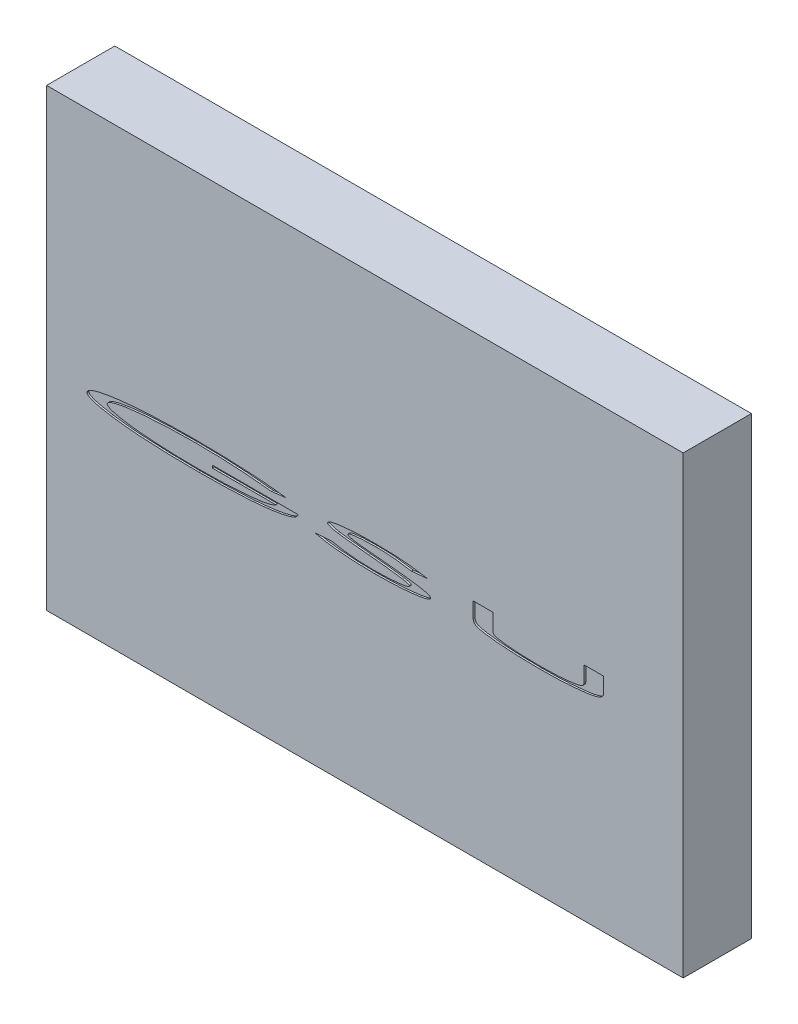
from build123d import *

# Parameters (mm, degrees)
SKETCH1_W           = 88.9
SKETCH1_H           = 63.5
BOSS_EXTRUDE1_DEPTH = 9.525
CUT_EXTRUDE1_DEPTH  = 0.254
SKETCH3_W           = 3.175
SKETCH3_H           = 8.119404955
BOSS_EXTRUDE2_DEPTH = 2.54


with BuildPart() as part:
    # Sketch1 → Boss-Extrude1 (new body)
    with BuildSketch(Plane.XY):
        with Locations((44.45, 31.75)):
            Rectangle(SKETCH1_W, SKETCH1_H)
    extrude(amount=BOSS_EXTRUDE1_DEPTH)

    # Sketch2 → Cut-Extrude1 (cut)
    with BuildSketch(Plane.XY.offset(9.525)):
        with BuildLine():
            Line((33.498393787, 30.350809785), (31.359972313, 30.095601452))
            add(Edge.make_bspline(
                [(31.359972313, 30.095601452), (31.164171604, 30.119137473), (30.76811553, 30.166744982), (30.166706814, 30.231507474), (29.551570327, 30.292530308), (28.922670707, 30.349476787), (28.279673094, 30.401057302), (27.622703221, 30.448744443), (26.95193934, 30.492152968), (26.270413682, 30.531082925), (25.584475752, 30.566046418), (24.8997008, 30.596305187), (24.219346058, 30.621254482), (23.543467912, 30.64262667), (22.87199923, 30.658484676), (22.204993407, 30.670596571), (21.542180258, 30.677844204), (21.101861062, 30.678572037), (20.88240821, 30.678934785)],
                knots=[0, 0, 0, 0, 0.901543175, 1.823597338, 2.765180975, 3.727432813, 4.710338068, 5.714059156, 6.738658915, 7.783129777, 8.834722104, 9.878489466, 10.916616063, 11.947049738, 12.969801264, 13.987077713, 14.996769752, 16, 16, 16, 16], degree=3))
            add(Edge.make_bspline(
                [(20.88240821, 30.678934785), (20.611771671, 30.678533034), (20.073752111, 30.677734362), (19.271653772, 30.667120378), (18.479352252, 30.652140424), (17.696872737, 30.630335379), (16.924205291, 30.602371737), (16.161122982, 30.567991839), (15.407841368, 30.527529146), (14.787679668, 30.488026119), (14.300667861, 30.454471855), (13.946820229, 30.427921112), (13.603534675, 30.399680287), (13.2706852, 30.371208245), (12.948211691, 30.340771958), (12.635913932, 30.310284713), (12.33418342, 30.278044793), (12.043035781, 30.244118788), (11.762030661, 30.210173759), (11.491453521, 30.174141603), (11.231251489, 30.137984115), (10.981402573, 30.100099786), (10.742115125, 30.060810447), (10.512990968, 30.021026291), (10.294519747, 29.979549511), (10.086678221, 29.937762848), (9.890320157, 29.895069357), (9.70638354, 29.851748365), (9.535056174, 29.808247615), (9.376422701, 29.765051074), (9.230465837, 29.721053436), (9.097283349, 29.676132736), (8.976664812, 29.631706908), (8.868950604, 29.586549428), (8.77339938, 29.542460718), (8.690800507, 29.496602594), (8.620438516, 29.451020239), (8.563050499, 29.404328981), (8.516857088, 29.358499552), (8.484728301, 29.310868581), (8.463756158, 29.262686858), (8.461184714, 29.22967111), (8.459932249, 29.213590234)],
                knots=[0, 0, 0, 0, 2.560295728, 5.08981227, 7.588659566, 10.05703186, 12.495103614, 14.903055874, 17.283284305, 19.631568545, 20.781808933, 21.901495378, 22.988464749, 24.04036836, 25.061839365, 26.052710236, 27.008843358, 27.932504729, 28.825690343, 29.686534002, 30.514814534, 31.310916308, 32.077131017, 32.808835325, 33.510877328, 34.180795271, 34.814382034, 35.411801099, 35.968416347, 36.486552916, 36.96706216, 37.410334263, 37.81609033, 38.182768289, 38.515088168, 38.811008814, 39.0759172, 39.306927123, 39.510190308, 39.688634681, 39.84834428, 40, 40, 40, 40], degree=3))
            add(Edge.make_bspline(
                [(8.459932249, 29.213590234), (8.461166338, 29.19727328), (8.463721069, 29.163494989), (8.485409294, 29.114021684), (8.51903134, 29.065208018), (8.5666102, 29.017751276), (8.625900688, 28.96982992), (8.698872961, 28.923518631), (8.784051754, 28.876108338), (8.882998824, 28.830857022), (8.99438579, 28.784160116), (9.119082119, 28.738142415), (9.257270777, 28.693052973), (9.407949999, 28.647338125), (9.571943548, 28.602656693), (9.74885068, 28.557843116), (9.939226664, 28.513902794), (10.141850219, 28.469876671), (10.356139437, 28.426419647), (10.581012117, 28.384462539), (10.815993417, 28.344093233), (11.060839734, 28.303782071), (11.315938945, 28.265725943), (11.580837619, 28.227348741), (11.856053676, 28.192085617), (12.140952083, 28.157079166), (12.43584492, 28.122487285), (12.740855683, 28.08964447), (13.055907253, 28.058143326), (13.38103884, 28.028182717), (13.716141724, 27.998528868), (14.061344864, 27.970597172), (14.41661488, 27.944136901), (14.906342471, 27.90905177), (15.533373432, 27.870463839), (16.300141908, 27.828517361), (17.084763843, 27.794527392), (17.887123565, 27.76682424), (18.706972206, 27.743855014), (19.544393733, 27.729219572), (20.399541334, 27.718557772), (20.97565393, 27.717786074), (21.266622954, 27.717396324)],
                knots=[0, 0, 0, 0, 0.149261413, 0.308991208, 0.488073047, 0.691343065, 0.923166096, 1.186735423, 1.483418409, 1.817363135, 2.184659931, 2.591878477, 3.036859013, 3.518657845, 4.036963324, 4.596752705, 5.193559406, 5.830130172, 6.49984963, 7.200332085, 7.929610585, 8.688147997, 9.477804936, 10.296861546, 11.144803288, 12.024397377, 12.931424197, 13.869946708, 14.840028511, 15.837455419, 16.866734368, 17.927713592, 19.016159642, 20.136539519, 22.434085388, 24.782026112, 27.184624724, 29.642192438, 32.150682135, 34.712293212, 37.329412879, 40, 40, 40, 40], degree=3))
            add(Edge.make_bspline(
                [(21.266622954, 27.717396324), (21.443306298, 27.717705721), (21.793170702, 27.718318383), (22.312939208, 27.721990144), (22.822433762, 27.727285388), (23.321632785, 27.735914276), (23.810319462, 27.746408156), (24.288739593, 27.758777137), (24.756850537, 27.774387035), (25.214689459, 27.791892583), (25.662270192, 27.811277419), (26.099526756, 27.833883997), (26.526518073, 27.858403169), (26.943029925, 27.884767236), (27.349194044, 27.914433701), (27.74510561, 27.945941574), (28.130791573, 27.979242834), (28.504656196, 28.016048918), (28.864005268, 28.052995455), (29.205802046, 28.093643703), (29.528975208, 28.133463694), (29.833143375, 28.176796036), (30.11872129, 28.219496768), (30.385046232, 28.265452416), (30.632682215, 28.311380875), (30.861478878, 28.358571004), (31.071211746, 28.408750089), (31.262520992, 28.458417683), (31.434828066, 28.510504037), (31.588531557, 28.562821804), (31.722899166, 28.618505699), (31.838957405, 28.674087426), (31.937191713, 28.73046153), (31.992116072, 28.774067505), (32.017624556, 28.794319401)],
                knots=[0, 0, 0, 0, 1.559717219, 3.088517121, 4.588489478, 6.057632978, 7.495954163, 8.903485704, 10.282390928, 11.630589239, 12.948120933, 14.237193767, 15.495701499, 16.723694437, 17.921374234, 19.090723157, 20.229747177, 21.338712889, 22.407039789, 23.418633316, 24.377225284, 25.281416395, 26.130789363, 26.926158043, 27.667056146, 28.354106116, 28.9881293, 29.570617496, 30.098632808, 30.576887523, 31.003318101, 31.38163322, 31.712812309, 32, 32, 32, 32], degree=3))
            Line((32.017624556, 28.794319401), (23.177880967, 28.794319401))
            Line((23.177880967, 28.794319401), (23.177880967, 29.15329376))
            Line((23.177880967, 29.15329376), (35.113778403, 29.15329376))
            add(Edge.make_bspline(
                [(35.113778403, 29.15329376), (35.112165747, 29.136151001), (35.108920439, 29.101652913), (35.094942791, 29.050794686), (35.074620932, 29.000433021), (35.045795333, 28.951236223), (35.010921679, 28.902145355), (34.968240774, 28.854131852), (34.917931033, 28.807170724), (34.860782184, 28.760553067), (34.796062475, 28.714559828), (34.724397553, 28.669462118), (34.645101774, 28.625174447), (34.559052484, 28.581194006), (34.46571577, 28.537430089), (34.3644653, 28.495992606), (34.256465375, 28.453539673), (34.140849559, 28.412492741), (34.018118025, 28.37184628), (33.888162157, 28.331823454), (33.750897374, 28.292742263), (33.606435946, 28.254217094), (33.454750832, 28.216313246), (33.295788393, 28.179249044), (33.129284381, 28.14299028), (32.955785876, 28.106234601), (32.77456303, 28.071350647), (32.586086584, 28.037334685), (32.390629855, 28.002489202), (32.187603732, 27.970029021), (31.977561558, 27.93690971), (31.760261729, 27.904480302), (31.535538878, 27.874056135), (31.223281979, 27.832209943), (30.818610896, 27.782869678), (30.317450596, 27.728473304), (29.796479607, 27.677405974), (29.255688195, 27.629535197), (28.694945387, 27.586517385), (28.114195157, 27.546274751), (27.513739947, 27.510932014), (26.893234797, 27.478631988), (26.252870525, 27.44986505), (25.592394021, 27.425313397), (24.912263698, 27.405529694), (24.212322992, 27.387545976), (23.492484872, 27.374381875), (22.752551437, 27.365524127), (21.99276055, 27.359735098), (21.47953133, 27.358863377), (21.219647794, 27.358421965)],
                knots=[0, 0, 0, 0, 0.173287774, 0.348724318, 0.529413354, 0.719357524, 0.922025509, 1.135679417, 1.365673011, 1.615149832, 1.878618212, 2.165563057, 2.468311752, 2.793895887, 3.139613543, 3.507144469, 3.896528235, 4.309367421, 4.743716078, 5.199789029, 5.680036688, 6.182366302, 6.706917049, 7.256105144, 7.827751413, 8.424737021, 9.043885989, 9.688069709, 10.35544506, 11.045264933, 11.76067648, 12.499023304, 13.260026326, 14.046711347, 15.674976355, 17.369487022, 19.128399383, 20.951901464, 22.842327179, 24.797685087, 26.820321237, 28.905814273, 31.061333963, 33.282186671, 35.568496213, 37.920489349, 40.340481978, 42.826216353, 45.380154639, 48, 48, 48, 48], degree=3))
            add(Edge.make_bspline(
                [(21.219647794, 27.358421965), (21.060960162, 27.358531984), (20.745453166, 27.358750726), (20.275469653, 27.361261628), (19.811550898, 27.363460253), (19.353959656, 27.368937668), (18.902429153, 27.374201389), (18.457214753, 27.381283229), (18.018310218, 27.389689088), (17.585712262, 27.399403211), (17.159444262, 27.410960368), (16.739437702, 27.422282626), (16.325573154, 27.436884875), (15.917965202, 27.45124961), (15.51645189, 27.467392209), (15.121275868, 27.485224429), (14.732329097, 27.50281258), (14.349807979, 27.523848386), (13.973468415, 27.544170647), (13.60310388, 27.567922983), (13.238945545, 27.591371283), (12.881133217, 27.616616806), (12.529680333, 27.643612028), (12.184396823, 27.670280968), (11.845377395, 27.700377396), (11.512747314, 27.730078656), (11.186266528, 27.761790969), (10.866075239, 27.794674213), (10.551952871, 27.828925747), (10.24422244, 27.865012201), (9.94259909, 27.900858589), (9.647330043, 27.940070822), (9.358113855, 27.978730246), (9.167571718, 28.006539016), (9.073413819, 28.020280939)],
                knots=[0, 0, 0, 0, 1.25133571, 2.487939159, 3.706123477, 4.909611371, 6.096535522, 7.266927036, 8.420799223, 9.558165973, 10.67904179, 11.783388008, 12.871328107, 13.944598398, 14.999593462, 16.040014038, 17.063949564, 18.069755188, 19.060939775, 20.035893706, 20.996252006, 21.938473619, 22.864422433, 23.775814375, 24.669297784, 25.54825852, 26.409214049, 27.255865198, 28.086411598, 28.900889254, 29.699112994, 30.481570037, 31.249655866, 32, 32, 32, 32], degree=3))
            add(Edge.make_bspline(
                [(9.073413819, 28.020280939), (9.002821451, 28.030948841), (8.863920321, 28.051939547), (8.65898321, 28.084360287), (8.460707258, 28.116310262), (8.269068532, 28.14932842), (8.084250404, 28.183027886), (7.906163058, 28.216686736), (7.734764249, 28.250157721), (7.570307722, 28.284671954), (7.412214603, 28.318815484), (7.261068436, 28.353962412), (7.116616526, 28.38896583), (6.978874013, 28.423960499), (6.847917805, 28.459517314), (6.723705746, 28.496221635), (6.6060849, 28.532507059), (6.4949292, 28.568853242), (6.390772452, 28.606073071), (6.293056441, 28.642902267), (6.202551995, 28.681061156), (6.118483094, 28.718637865), (6.040968491, 28.756550699), (5.970140123, 28.794845054), (5.906321054, 28.834069052), (5.849334012, 28.873530503), (5.798381633, 28.912401615), (5.754965357, 28.952706984), (5.717124387, 28.992404523), (5.687027624, 29.033420988), (5.66245576, 29.074185425), (5.64554965, 29.115815061), (5.635260702, 29.157705481), (5.633753702, 29.185724881), (5.633009172, 29.199567798)],
                knots=[0, 0, 0, 0, 1.822223928, 3.585500351, 5.295765701, 6.948182563, 8.548774514, 10.090715014, 11.574083748, 13.00601978, 14.379615137, 15.702136353, 16.96661525, 18.173208705, 19.329414063, 20.429849322, 21.478885095, 22.471094327, 23.414440792, 24.301811497, 25.136002493, 25.92094558, 26.651902042, 27.337909187, 27.975277371, 28.562676203, 29.106772842, 29.609149393, 30.073428365, 30.504111874, 30.905148094, 31.285089726, 31.646800292, 32, 32, 32, 32], degree=3))
            add(Edge.make_bspline(
                [(5.633009172, 29.199567798), (5.634569981, 29.220338011), (5.637784864, 29.263119523), (5.662908983, 29.325947898), (5.702475987, 29.387591529), (5.757657554, 29.448095091), (5.828158559, 29.507487006), (5.913195444, 29.567080496), (6.014555261, 29.624901621), (6.130735055, 29.682759338), (6.262472388, 29.739936414), (6.40887957, 29.797632147), (6.571346245, 29.853040326), (6.748654513, 29.90933313), (6.941939107, 29.96432186), (7.150289493, 30.019874815), (7.374473381, 30.073296434), (7.612732167, 30.127487749), (7.864879994, 30.179426831), (8.128826425, 30.231685793), (8.404729148, 30.281156408), (8.69197947, 30.329488898), (8.990685375, 30.376394064), (9.30060096, 30.421933968), (9.621969917, 30.466037711), (9.954730254, 30.509013449), (10.299346951, 30.549117858), (10.655179006, 30.589642079), (11.022698099, 30.626795925), (11.40120371, 30.664595476), (11.791371937, 30.698993049), (12.19280255, 30.733871588), (12.606051926, 30.76579249), (13.030007747, 30.796547808), (13.463286912, 30.826061045), (13.904300427, 30.853408466), (14.352349538, 30.878396289), (14.80735838, 30.9024521), (15.269638968, 30.924188473), (15.738949134, 30.94352841), (16.215229625, 30.962021296), (16.698545397, 30.978054925), (17.188867651, 30.99212296), (17.68644581, 31.003777003), (18.191012552, 31.014594553), (18.702611018, 31.022661389), (19.221203454, 31.029958286), (19.746817048, 31.034738151), (20.279673704, 31.03766559), (20.637248901, 31.037827607), (20.817203883, 31.037909144)],
                knots=[0, 0, 0, 0, 0.192161926, 0.395806149, 0.618828282, 0.868950107, 1.15168167, 1.472089154, 1.830351652, 2.232495172, 2.67493025, 3.161398823, 3.691095085, 4.266047719, 4.886016421, 5.554025888, 6.265084938, 7.022565255, 7.819360025, 8.651829877, 9.517165752, 10.418044808, 11.352446437, 12.320470786, 13.322207914, 14.359888197, 15.431181917, 16.538821552, 17.6802356, 18.855927486, 20.065527521, 21.311632913, 22.591761846, 23.908296688, 25.252627148, 26.618158967, 28.00493704, 29.413115926, 30.842613354, 32.295633707, 33.767966254, 35.261720121, 36.779096121, 38.315795872, 39.876227354, 41.458201966, 43.05961064, 44.684778251, 46.331565847, 48, 48, 48, 48], degree=3))
            add(Edge.make_bspline(
                [(20.817203883, 31.037909144), (21.108171102, 31.037326557), (21.685908828, 31.036169786), (22.546200637, 31.028243301), (23.393637374, 31.015667738), (24.228002487, 30.9984198), (25.049257592, 30.975081646), (25.857668755, 30.94708057), (26.653250322, 30.914388857), (27.437356997, 30.875700193), (28.212578793, 30.831403531), (28.981764206, 30.78184329), (29.746015205, 30.725729067), (30.505588866, 30.663292324), (31.260508598, 30.594731686), (32.01067643, 30.519373812), (32.756324951, 30.439343818), (33.251420718, 30.38027541), (33.498393787, 30.350809785)],
                knots=[0, 0, 0, 0, 1.099049298, 2.182246661, 3.249628992, 4.300352282, 5.334481619, 6.352923092, 7.355721137, 8.342083628, 9.318242783, 10.288663195, 11.253466222, 12.212724579, 13.16739138, 14.116662011, 15.060517593, 16, 16, 16, 16], degree=3))
        make_face()
        with BuildLine():
            Line((37.491983531, 28.123345843), (39.836534813, 28.300729657))
            add(Edge.make_bspline(
                [(39.836534813, 28.300729657), (39.940909195, 28.276701899), (40.151101935, 28.228313969), (40.470564482, 28.162950174), (40.795818067, 28.100888582), (41.127380242, 28.044550553), (41.464577471, 27.991662036), (41.808003999, 27.944236207), (42.157384886, 27.900583055), (42.512955366, 27.862383766), (42.874247504, 27.827677379), (43.241489539, 27.798659612), (43.61494518, 27.773035121), (43.994321764, 27.753176087), (44.379942516, 27.736652418), (44.771450543, 27.725909387), (45.169003824, 27.718379693), (45.435923541, 27.717725625), (45.570308851, 27.717396324)],
                knots=[0, 0, 0, 0, 0.890039688, 1.79239271, 2.709628017, 3.641651651, 4.587128132, 5.545992639, 6.522592302, 7.513054383, 8.517794023, 9.538759981, 10.574362482, 11.628529543, 12.695721439, 13.781844458, 14.883231538, 16, 16, 16, 16], degree=3))
            add(Edge.make_bspline(
                [(45.570308851, 27.717396324), (45.685293554, 27.717724416), (45.913632086, 27.718375947), (46.253689434, 27.721801053), (46.588607174, 27.728031183), (46.918131535, 27.737373601), (47.24207697, 27.748331409), (47.560636548, 27.762350535), (47.874026317, 27.779368928), (48.180212455, 27.797985974), (48.474721141, 27.818730337), (48.752875216, 27.84166007), (49.01274531, 27.867047104), (49.254432839, 27.893555457), (49.478209144, 27.921203367), (49.683412731, 27.951381016), (49.870528468, 27.982626868), (50.039129949, 28.015990422), (50.188714811, 28.050918288), (50.318913356, 28.085587908), (50.429255337, 28.120658366), (50.519383898, 28.156990976), (50.590878313, 28.192405819), (50.641778572, 28.229358181), (50.677251796, 28.267657809), (50.682102542, 28.297210871), (50.684291223, 28.310545362)],
                knots=[0, 0, 0, 0, 1.585696951, 3.148903322, 4.689739136, 6.205097755, 7.694986232, 9.159617673, 10.60234449, 12.023103138, 13.38982885, 14.673746672, 15.871863689, 16.990500619, 18.026667845, 18.981102819, 19.850584646, 20.642567967, 21.350851397, 21.968487114, 22.500515437, 22.945793925, 23.309057408, 23.594610146, 23.817086036, 24, 24, 24, 24], degree=3))
            add(Edge.make_bspline(
                [(50.684291223, 28.310545362), (50.68360697, 28.317929082), (50.682162523, 28.333515979), (50.669410407, 28.355628748), (50.650750166, 28.377722561), (50.624213707, 28.399108774), (50.591029768, 28.420751523), (50.550671288, 28.442506663), (50.502793896, 28.4640157), (50.447631721, 28.485726885), (50.384848697, 28.506220519), (50.315480406, 28.528472728), (50.238138452, 28.549130154), (50.153397806, 28.569852918), (50.061733979, 28.591972664), (49.962507794, 28.61271217), (49.856166817, 28.633763683), (49.782667025, 28.647180515), (49.744788018, 28.654095042)],
                knots=[0, 0, 0, 0, 0.341635525, 0.721186276, 1.161385129, 1.686558295, 2.299126142, 3.005062605, 3.818147991, 4.741465614, 5.763306975, 6.891987576, 8.132486074, 9.488811948, 10.95344095, 12.521844396, 14.207490401, 16, 16, 16, 16], degree=3))
            add(Edge.make_bspline(
                [(49.744788018, 28.654095042), (49.688020249, 28.664047397), (49.568997348, 28.684914134), (49.381747122, 28.714830551), (49.177933002, 28.745578925), (48.95731702, 28.777204837), (48.720069561, 28.809237572), (48.465813479, 28.84236137), (48.194857744, 28.875547205), (47.907283339, 28.911145235), (47.602917306, 28.945797203), (47.282046454, 28.981649497), (46.944285207, 29.017847501), (46.590079804, 29.056154214), (46.218611609, 29.093454123), (45.830755412, 29.133234262), (45.425878315, 29.171999384), (45.150568397, 29.198611295), (45.010112537, 29.21218799)],
                knots=[0, 0, 0, 0, 0.580143207, 1.216364995, 1.908735512, 2.654980302, 3.459799983, 4.318567275, 5.235976398, 6.207663663, 7.235419392, 8.319542168, 9.457707194, 10.654851853, 11.905812593, 13.215761226, 14.5795548, 16, 16, 16, 16], degree=3))
            add(Edge.make_bspline(
                [(45.010112537, 29.21218799), (44.869425103, 29.22578781), (44.594832123, 29.252331866), (44.19322932, 29.290397905), (43.812099609, 29.328517377), (43.451533019, 29.365169451), (43.111147116, 29.398946925), (42.791323826, 29.433305572), (42.491573093, 29.464040879), (42.212420617, 29.495599796), (41.953574432, 29.523652889), (41.715534595, 29.552177034), (41.497657794, 29.577848845), (41.300186519, 29.602485759), (41.122920215, 29.625059997), (40.966251267, 29.648112374), (40.829854789, 29.667765853), (40.745868996, 29.681806475), (40.707328082, 29.688249689)],
                knots=[0, 0, 0, 0, 1.567000881, 3.058463921, 4.472313514, 5.8134601, 7.076489226, 8.264510071, 9.379568, 10.417066139, 11.379026485, 12.26603991, 13.074948862, 13.811215231, 14.472289434, 15.055999585, 15.56680008, 16, 16, 16, 16], degree=3))
            add(Edge.make_bspline(
                [(40.707328082, 29.688249689), (40.648164269, 29.698331765), (40.533422277, 29.71788489), (40.367532159, 29.749545606), (40.213044604, 29.781122748), (40.069857235, 29.812326204), (39.938109691, 29.844747965), (39.817544851, 29.876603858), (39.708671841, 29.909225576), (39.611759955, 29.94346892), (39.525368735, 29.975531422), (39.450646624, 30.009238982), (39.387369857, 30.043163124), (39.335420281, 30.077765919), (39.293954545, 30.111960186), (39.265306197, 30.147939141), (39.245311645, 30.183672112), (39.243063081, 30.208960924), (39.241983531, 30.221102253)],
                knots=[0, 0, 0, 0, 1.788187297, 3.468001211, 5.031670917, 6.486357443, 7.834096939, 9.073897133, 10.201754879, 11.219175806, 12.136074952, 12.946348015, 13.659919355, 14.272145421, 14.805380915, 15.251256814, 15.640523358, 16, 16, 16, 16], degree=3))
            add(Edge.make_bspline(
                [(39.241983531, 30.221102253), (39.242748902, 30.230524338), (39.244318908, 30.249851855), (39.254666132, 30.278435311), (39.272209302, 30.306237696), (39.296552247, 30.333389664), (39.326842608, 30.360998151), (39.364622602, 30.3874082), (39.408656188, 30.413872289), (39.459451705, 30.439956098), (39.517252808, 30.464573447), (39.580947529, 30.490990041), (39.651919099, 30.516018776), (39.729728117, 30.540186975), (39.813965895, 30.565043193), (39.905285469, 30.588566923), (40.003242235, 30.612299596), (40.107641697, 30.636271772), (40.218241574, 30.659224541), (40.334642414, 30.681645747), (40.456426071, 30.703326344), (40.583867434, 30.724191465), (40.716495518, 30.745579346), (40.8549975, 30.764722592), (40.998663404, 30.784597576), (41.14773811, 30.803641548), (41.302554648, 30.820798575), (41.462602122, 30.838491162), (41.628533055, 30.855398035), (41.799901607, 30.871123605), (41.976732865, 30.887776083), (42.158845947, 30.902160669), (42.346537431, 30.916091645), (42.605399924, 30.935114744), (42.93701361, 30.956007545), (43.341834066, 30.977505845), (43.755257389, 30.996608988), (44.177107525, 31.012196705), (44.607637782, 31.022982259), (45.046781008, 31.03133707), (45.494336666, 31.037492157), (45.795600533, 31.037769363), (45.947512377, 31.037909144)],
                knots=[0, 0, 0, 0, 0.164718869, 0.337887745, 0.525005882, 0.736423345, 0.973632595, 1.240112436, 1.540744767, 1.871522872, 2.237457791, 2.638860526, 3.076996523, 3.552575016, 4.063346547, 4.612416203, 5.201108701, 5.825598287, 6.48514497, 7.175937738, 7.898127503, 8.647814843, 9.433805769, 10.246871909, 11.092314674, 11.969634032, 12.874377531, 13.81567057, 14.78498091, 15.790494833, 16.824490205, 17.890354746, 18.984419259, 20.115159918, 22.428528935, 24.793730953, 27.203013792, 29.664531554, 32.174293012, 34.732706774, 37.343975463, 40, 40, 40, 40], degree=3))
            add(Edge.make_bspline(
                [(45.947512377, 31.037909144), (46.109005491, 31.03744827), (46.429196725, 31.036534498), (46.905747764, 31.030957336), (47.374350868, 31.02117157), (47.835014773, 31.007269133), (48.287469748, 30.988774774), (48.732032612, 30.967423108), (49.168815935, 30.941114533), (49.600112925, 30.912118892), (50.030619991, 30.876577049), (50.464945632, 30.835551629), (50.905449663, 30.78672672), (51.35194261, 30.732403932), (51.804570355, 30.670197118), (52.26345605, 30.602537784), (52.728517428, 30.527396624), (53.040118646, 30.472912033), (53.197111736, 30.445461228)],
                knots=[0, 0, 0, 0, 1.064177452, 2.109936975, 3.140449097, 4.152723871, 5.146856169, 6.124407808, 7.085543109, 8.030264259, 8.972839003, 9.931977154, 10.904942246, 11.893274638, 12.895802622, 13.915529873, 14.94978778, 16, 16, 16, 16], degree=3))
            Line((53.197111736, 30.445461228), (50.946510774, 30.230216837))
            add(Edge.make_bspline(
                [(50.946510774, 30.230216837), (50.818722438, 30.252480028), (50.568028545, 30.296155737), (50.198422164, 30.355396472), (49.843479528, 30.4096527), (49.502682713, 30.45736493), (49.176636568, 30.499403701), (48.86486377, 30.535987274), (48.567615041, 30.567204415), (48.280999786, 30.591864169), (47.99860152, 30.611991343), (47.713760578, 30.630832105), (47.422717438, 30.644849844), (47.125472763, 30.658108042), (46.821835379, 30.666591536), (46.511944044, 30.673895826), (46.195954995, 30.678124123), (45.983270752, 30.678662993), (45.875997954, 30.678934785)],
                knots=[0, 0, 0, 0, 1.22129439, 2.395923229, 3.524348983, 4.602010157, 5.635888739, 6.61957021, 7.557575061, 8.449890351, 9.327994811, 10.223211199, 11.137570094, 12.071405072, 13.02463314, 13.997484906, 14.989979733, 16, 16, 16, 16], degree=3))
            add(Edge.make_bspline(
                [(45.875997954, 30.678934785), (45.739511761, 30.678461473), (45.472837817, 30.677536692), (45.082269305, 30.672360856), (44.710663066, 30.661553256), (44.358210519, 30.647606076), (44.02483718, 30.630730141), (43.710751283, 30.607859821), (43.415681952, 30.582571804), (43.182580674, 30.556804125), (43.007581791, 30.535231956), (42.887038151, 30.518206382), (42.774560053, 30.501538214), (42.67047388, 30.484341414), (42.574790148, 30.465593053), (42.487257241, 30.448363084), (42.408643717, 30.427751693), (42.337564194, 30.409815373), (42.275265942, 30.389262327), (42.221089281, 30.368783165), (42.174360044, 30.349463421), (42.137138771, 30.327103249), (42.106742527, 30.30621018), (42.086086488, 30.283177249), (42.071550115, 30.260237182), (42.069760831, 30.243714103), (42.068906608, 30.235825811)],
                knots=[0, 0, 0, 0, 2.525181992, 4.933834176, 7.226410698, 9.40304327, 11.459731204, 13.401766853, 15.22913896, 16.938566973, 17.740353253, 18.491266516, 19.190827769, 19.844092201, 20.442790214, 20.994843793, 21.494023128, 21.946070748, 22.350810379, 22.706579655, 23.018289461, 23.283777391, 23.5094908, 23.696220554, 23.854972498, 24, 24, 24, 24], degree=3))
            add(Edge.make_bspline(
                [(42.068906608, 30.235825811), (42.070038662, 30.22620528), (42.072494683, 30.205333299), (42.093696837, 30.1772845), (42.12281988, 30.148418693), (42.165596745, 30.122266911), (42.218059045, 30.0934284), (42.283782092, 30.068362502), (42.359754656, 30.04013601), (42.449328757, 30.013731198), (42.554441722, 29.987165865), (42.677265059, 29.958863079), (42.819796321, 29.931369667), (42.981787155, 29.902711516), (43.163122928, 29.873213268), (43.364040445, 29.844331813), (43.583836127, 29.813004206), (43.737079301, 29.793663929), (43.816803242, 29.783602253)],
                knots=[0, 0, 0, 0, 0.247734471, 0.537466101, 0.885332832, 1.314851085, 1.83106381, 2.44119035, 3.138538812, 3.937790799, 4.865762266, 5.955962431, 7.212505335, 8.637315102, 10.230792775, 11.986325769, 13.911907433, 16, 16, 16, 16], degree=3))
            add(Edge.make_bspline(
                [(43.816803242, 29.783602253), (43.842745702, 29.780573762), (43.901167189, 29.773753708), (43.998299546, 29.762166278), (44.115084104, 29.751081106), (44.250703234, 29.735487586), (44.406003677, 29.7207382), (44.580562338, 29.703012433), (44.774739215, 29.683273755), (44.988354416, 29.662301085), (45.221400305, 29.640041775), (45.473529839, 29.615316376), (45.745097146, 29.589363326), (46.036107514, 29.562260728), (46.346423454, 29.532545336), (46.676233064, 29.501979293), (47.02534273, 29.468738533), (47.264681657, 29.446544528), (47.387616544, 29.435144721)],
                knots=[0, 0, 0, 0, 0.349432378, 0.786909147, 1.308650832, 1.918768058, 2.613177267, 3.395632072, 4.266132919, 5.224369016, 6.267233869, 7.398141923, 8.613680539, 9.916965346, 11.308290949, 12.784250997, 14.348251398, 16, 16, 16, 16], degree=3))
            add(Edge.make_bspline(
                [(47.387616544, 29.435144721), (47.534157051, 29.421185205), (47.821657915, 29.393797739), (48.24397402, 29.352490419), (48.64875698, 29.3118289), (49.035772719, 29.271820382), (49.405321871, 29.232835567), (49.757014692, 29.193438297), (50.091213494, 29.154838397), (50.407678108, 29.117155149), (50.706575803, 29.079865098), (50.987820639, 29.043835605), (51.251308898, 29.006842188), (51.497569843, 28.972430871), (51.726060399, 28.937045652), (51.9372342, 28.903189443), (52.130382547, 28.868496258), (52.307201122, 28.835716768), (52.469776667, 28.802255386), (52.62104699, 28.769523609), (52.762006046, 28.736623593), (52.892463045, 28.70376385), (53.012415919, 28.67091385), (53.121862822, 28.638064942), (53.220836384, 28.605283765), (53.309462708, 28.572284531), (53.38782155, 28.539808614), (53.455917045, 28.506884505), (53.513221817, 28.47338307), (53.560862972, 28.440717084), (53.598191374, 28.407839169), (53.624914135, 28.374335335), (53.642865511, 28.340469213), (53.644879663, 28.316801118), (53.645829685, 28.30563751)],
                knots=[0, 0, 0, 0, 2.193074481, 4.30263838, 6.321773214, 8.253957863, 10.099207885, 11.857923758, 13.526297305, 15.11127167, 16.605962607, 18.013862988, 19.335488026, 20.569944478, 21.718290975, 22.780115011, 23.756124701, 24.641828998, 25.459197077, 26.228868495, 26.94759254, 27.615566941, 28.233038178, 28.80031857, 29.317811315, 29.786048246, 30.208956907, 30.581121036, 30.911948978, 31.196905748, 31.440956297, 31.649226229, 31.834549389, 32, 32, 32, 32], degree=3))
            add(Edge.make_bspline(
                [(53.645829685, 28.30563751), (53.643906185, 28.289384634), (53.639866752, 28.255252871), (53.609288877, 28.207470085), (53.564172657, 28.160895842), (53.499976464, 28.116511045), (53.419012243, 28.073072028), (53.320744654, 28.029636965), (53.204688265, 27.987311066), (53.070751819, 27.945627279), (52.919139133, 27.904568287), (52.749944605, 27.863742819), (52.562655313, 27.825301283), (52.357845582, 27.785526156), (52.134937303, 27.748260656), (51.894435256, 27.711094924), (51.636157654, 27.674697974), (51.361747386, 27.63935916), (51.074569064, 27.604886664), (50.777865874, 27.573938501), (50.473895782, 27.543292831), (50.162064689, 27.516253236), (49.842579629, 27.490972159), (49.515136625, 27.467966594), (49.180251814, 27.446651229), (48.837572432, 27.428994634), (48.487287084, 27.411555243), (48.129191793, 27.398241084), (47.763470153, 27.385006659), (47.390210874, 27.375587471), (47.009030525, 27.367846947), (46.620371788, 27.362023771), (46.223757275, 27.359599115), (45.9568608, 27.358817085), (45.822011576, 27.358421965)],
                knots=[0, 0, 0, 0, 0.194194747, 0.407817623, 0.663750385, 0.971240949, 1.339049841, 1.765973197, 2.259415095, 2.82098398, 3.449061045, 4.144368741, 4.909600849, 5.743589028, 6.648350158, 7.621885196, 8.664381741, 9.778774217, 10.942581228, 12.135793898, 13.359126999, 14.60934486, 15.89240737, 17.205611508, 18.549042377, 19.919826639, 21.323944289, 22.758399679, 24.220679626, 25.716263367, 27.239694009, 28.796633946, 30.381501935, 32, 32, 32, 32], degree=3))
            add(Edge.make_bspline(
                [(45.822011576, 27.358421965), (45.61494346, 27.358923772), (45.205697773, 27.359915534), (44.599212289, 27.368906033), (44.007175147, 27.381512111), (43.429915847, 27.401625326), (42.867094628, 27.425803816), (42.319241927, 27.455890985), (41.785879924, 27.49162127), (41.266510932, 27.532881282), (40.759223155, 27.580222541), (40.263043022, 27.635838046), (39.776776901, 27.697869287), (39.300491918, 27.768340917), (38.833791469, 27.844889744), (38.377389712, 27.930108367), (37.930707751, 28.021261611), (37.637437839, 28.089500911), (37.491983531, 28.123345843)],
                knots=[0, 0, 0, 0, 1.185505446, 2.343011577, 3.472593857, 4.575765801, 5.649886148, 6.697805193, 7.716993992, 8.71027727, 9.680609137, 10.633812505, 11.568681914, 12.487003432, 13.39020348, 14.276178507, 15.145029022, 16, 16, 16, 16], degree=3))
        make_face()
        with BuildLine():
            Line((59.568906608, 30.948165555), (62.306086095, 30.948165555))
            Line((62.306086095, 30.948165555), (62.306086095, 28.851110266))
            add(Edge.make_bspline(
                [(62.306086095, 28.851110266), (62.306599314, 28.821427291), (62.307573956, 28.765057016), (62.311863529, 28.68469395), (62.321287403, 28.613382061), (62.332430776, 28.550293186), (62.34864084, 28.496362398), (62.367215686, 28.450519219), (62.38987547, 28.413234943), (62.409240313, 28.394361595), (62.418265582, 28.385565394)],
                knots=[0, 0, 0, 0, 1.452135837, 2.757718666, 3.933107346, 4.96885502, 5.887465526, 6.681484804, 7.385486668, 8, 8, 8, 8], degree=3))
            add(Edge.make_bspline(
                [(62.418265582, 28.385565394), (62.43789746, 28.368118118), (62.480016222, 28.33068626), (62.558730485, 28.283902289), (62.652893047, 28.237604966), (62.764601105, 28.194321098), (62.892709081, 28.151979418), (63.038149702, 28.113627002), (63.200116043, 28.075725808), (63.346206449, 28.046469335), (63.472669413, 28.024688716), (63.575976473, 28.007900093), (63.685478385, 27.990724114), (63.80160118, 27.976036069), (63.923463806, 27.95935756), (64.051799177, 27.94408055), (64.186467496, 27.929584764), (64.327345593, 27.914600315), (64.474632661, 27.900832586), (64.628183693, 27.886883025), (64.787961617, 27.872337871), (64.954249966, 27.860533558), (65.126414869, 27.846666907), (65.304977851, 27.834116935), (65.48987131, 27.822424984), (65.874862959, 27.798170458), (66.458820823, 27.768203583), (67.240163803, 27.738596493), (68.023881228, 27.720486994), (68.546995526, 27.718427697), (68.808990742, 27.717396324)],
                knots=[0, 0, 0, 0, 0.339982398, 0.729407441, 1.182185488, 1.700602265, 2.281488521, 2.931504761, 3.650591999, 4.438858303, 4.863444247, 5.314931849, 5.796360241, 6.300936182, 6.832954662, 7.39166031, 7.977123553, 8.589713143, 9.229147721, 9.895745325, 10.589515205, 11.309981106, 12.057879728, 12.829738093, 13.631635105, 14.460758481, 17.833019448, 21.215216207, 24.601926382, 28, 28, 28, 28], degree=3))
            add(Edge.make_bspline(
                [(68.808990742, 27.717396324), (69.03475719, 27.718458702), (69.481420957, 27.720560546), (70.14454317, 27.733681971), (70.79334206, 27.757337272), (71.323883705, 27.782758076), (71.736016191, 27.809302475), (72.030730017, 27.830313731), (72.312401582, 27.852477363), (72.581190472, 27.876973638), (72.837084013, 27.903713417), (73.080164361, 27.931666653), (73.310460907, 27.960825421), (73.527546622, 27.992533319), (73.731263594, 28.024976324), (73.921089811, 28.060058694), (74.096858393, 28.097153801), (74.258721826, 28.135408302), (74.406315193, 28.17527706), (74.539942472, 28.216593312), (74.659991117, 28.259030702), (74.733656981, 28.29209175), (74.768525999, 28.307740875)],
                knots=[0, 0, 0, 0, 2.2522741, 4.455973154, 6.616299213, 8.728900387, 9.75450227, 10.736221012, 11.676442938, 12.573122673, 13.428714312, 14.243097215, 15.014068382, 15.744404114, 16.431658646, 17.071862652, 17.669969341, 18.223597737, 18.730924905, 19.19477334, 19.61885382, 20, 20, 20, 20], degree=3))
            add(Edge.make_bspline(
                [(74.768525999, 28.307740875), (74.790981925, 28.319349892), (74.835180523, 28.342199196), (74.892743637, 28.389830275), (74.941285312, 28.445766853), (74.982073641, 28.509789342), (75.012910985, 28.583062833), (75.034039414, 28.665044973), (75.047736118, 28.755300304), (75.049012336, 28.818337421), (75.049675838, 28.851110266)],
                knots=[0, 0, 0, 0, 0.932864555, 1.83609902, 2.742842969, 3.663775138, 4.63201772, 5.669991289, 6.788634063, 8, 8, 8, 8], degree=3))
            Line((75.049675838, 28.851110266), (75.049675838, 30.948165555))
            Line((75.049675838, 30.948165555), (77.786855326, 30.948165555))
            Line((77.786855326, 30.948165555), (77.786855326, 28.834283343))
            add(Edge.make_bspline(
                [(77.786855326, 28.834283343), (77.786342575, 28.814852035), (77.785330659, 28.776504182), (77.776433539, 28.719687863), (77.762673509, 28.664411291), (77.742589892, 28.610499152), (77.717292994, 28.557919233), (77.686585461, 28.506352927), (77.648595632, 28.457481486), (77.606685343, 28.408817671), (77.558966561, 28.361780875), (77.504979424, 28.317056693), (77.446362513, 28.272406844), (77.380687909, 28.231067614), (77.310614978, 28.189373345), (77.234765385, 28.149150624), (77.152544292, 28.112070535), (77.064883054, 28.073954122), (76.968246351, 28.03791689), (76.861082713, 28.003548518), (76.743087021, 27.967860207), (76.613220285, 27.93501097), (76.47260481, 27.90119132), (76.320653857, 27.868262179), (76.157475998, 27.83613277), (75.982790644, 27.804845125), (75.797263023, 27.77326048), (75.600538927, 27.742130757), (75.392380564, 27.713225466), (75.172927889, 27.683779417), (74.942122616, 27.653936837), (74.699914126, 27.626294775), (74.446532282, 27.599090904), (74.182972198, 27.571568992), (73.910250744, 27.545543572), (73.629472882, 27.522291838), (73.341886079, 27.498368531), (73.046827741, 27.478883224), (72.744939552, 27.458719166), (72.435727104, 27.44125509), (72.119703713, 27.426332626), (71.796527583, 27.411069825), (71.466281653, 27.398631017), (71.128791386, 27.388255138), (70.784536586, 27.379180339), (70.433045148, 27.371239892), (70.074524532, 27.365900288), (69.708770875, 27.361703678), (69.336005811, 27.358629904), (69.084999654, 27.358491706), (68.958329685, 27.358421965)],
                knots=[0, 0, 0, 0, 0.301423082, 0.594861053, 0.8904658, 1.184262278, 1.486034381, 1.795215151, 2.113703601, 2.445387032, 2.79166539, 3.152075727, 3.53295204, 3.934414537, 4.355582879, 4.798555796, 5.265983129, 5.755143559, 6.282015434, 6.865890582, 7.501709643, 8.194997441, 8.944605122, 9.746456013, 10.607952413, 11.525804817, 12.500824967, 13.528959074, 14.617013866, 15.762564015, 16.965661663, 18.229098997, 19.546207508, 20.921032696, 22.342068422, 23.798257953, 25.293914577, 26.821047221, 28.387749486, 29.989998369, 31.627898067, 33.298236934, 35.011611187, 36.757235635, 38.538909977, 40.356672083, 42.21412423, 44.104121538, 46.033949402, 48, 48, 48, 48], degree=3))
            add(Edge.make_bspline(
                [(68.958329685, 27.358421965), (68.820908974, 27.358467493), (68.548401601, 27.358557775), (68.143391142, 27.361991471), (67.745841811, 27.364862387), (67.355789112, 27.370899605), (66.973192008, 27.377443167), (66.598113867, 27.387156948), (66.230458933, 27.396355966), (65.870098272, 27.408697338), (65.517165689, 27.421518604), (65.171790499, 27.437576718), (64.833792592, 27.453082327), (64.503354797, 27.471658621), (64.180093415, 27.490931688), (63.864646379, 27.513132286), (63.556310649, 27.535078261), (63.256478353, 27.559709938), (62.966464757, 27.58566621), (62.687824833, 27.61201555), (62.421670598, 27.640282692), (62.167554513, 27.668699089), (61.925942264, 27.699050986), (61.696352941, 27.729591959), (61.479269248, 27.761949269), (61.274507539, 27.794791755), (61.081859151, 27.828393019), (60.901551503, 27.863045107), (60.733571312, 27.899729404), (60.577880721, 27.936831842), (60.434105059, 27.974145904), (60.302883226, 28.013786356), (60.183407204, 28.052822928), (60.109102787, 28.082546812), (60.0737143, 28.096703215)],
                knots=[0, 0, 0, 0, 1.475023383, 2.924993957, 4.347391178, 5.742283531, 7.112175821, 8.454640625, 9.769584415, 11.059678767, 12.324880772, 13.560315485, 14.770807335, 15.956633007, 17.112696931, 18.246717738, 19.350888397, 20.430627459, 21.475800758, 22.476242683, 23.434754296, 24.348651435, 25.220793829, 26.048478838, 26.834640883, 27.576562391, 28.274369378, 28.933614333, 29.547181772, 30.119728102, 30.651520736, 31.141200248, 31.590984955, 32, 32, 32, 32], degree=3))
            add(Edge.make_bspline(
                [(60.0737143, 28.096703215), (60.033641884, 28.114286833), (59.956238561, 28.148251105), (59.852714909, 28.215978389), (59.764597211, 28.293322494), (59.692541334, 28.381681189), (59.636443456, 28.480222128), (59.597251975, 28.589328355), (59.572713819, 28.70839214), (59.570203803, 28.79138963), (59.568906608, 28.834283343)],
                knots=[0, 0, 0, 0, 1.096330373, 2.117656562, 3.089567068, 4.027289542, 4.964737006, 5.920039447, 6.925061101, 8, 8, 8, 8], degree=3))
            Line((59.568906608, 28.834283343), (59.568906608, 30.948165555))
        make_face()
    extrude(amount=-CUT_EXTRUDE1_DEPTH, mode=Mode.SUBTRACT)

    # Sketch3 → Boss-Extrude2 (add)
    with BuildSketch(Plane.ZY):
        with Locations((1.5875, 16.260297523)):
            Rectangle(SKETCH3_W, SKETCH3_H)
    extrude(amount=BOSS_EXTRUDE2_DEPTH)


solid = part.part
